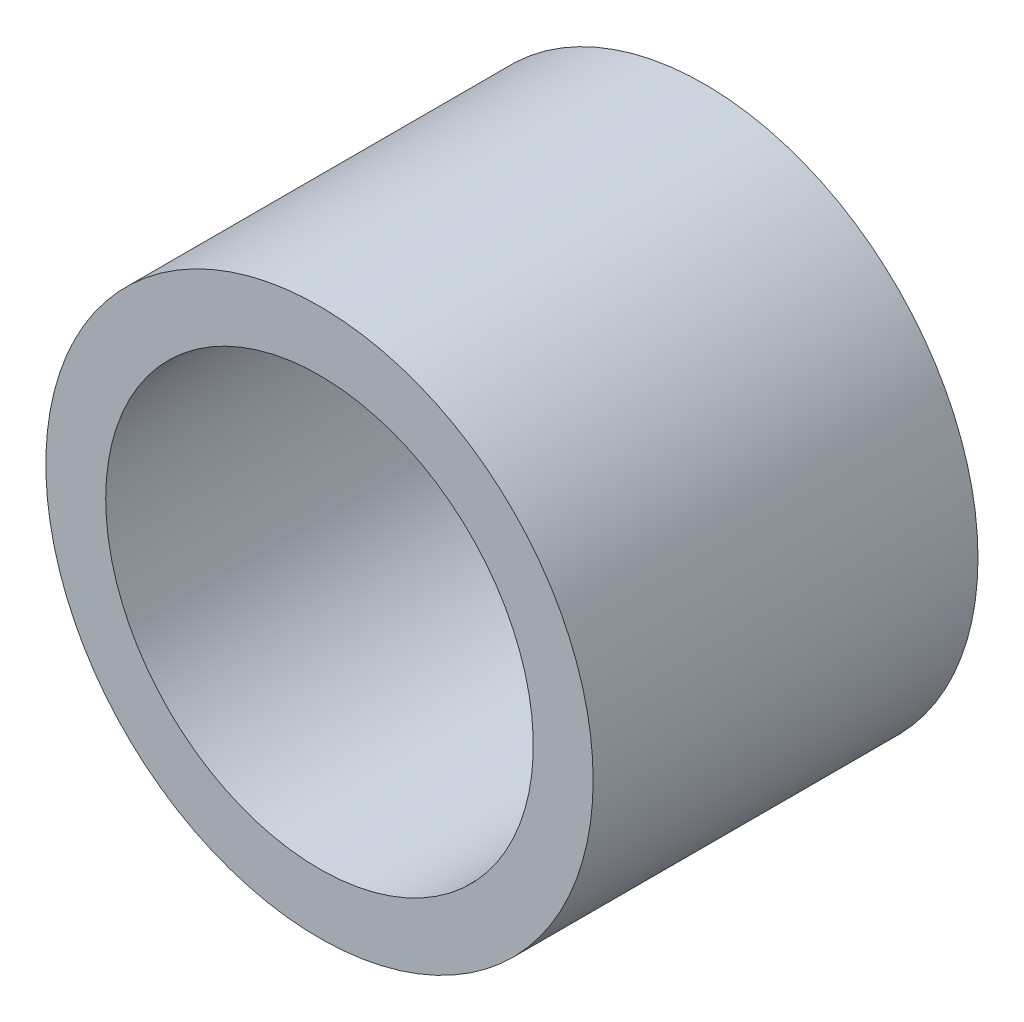
from build123d import *

# Parameters (mm, degrees)
SKETCH_1_R          = 16
EXTRUDE_1_DEPTH     = 22.5
SKETCH_2_R          = 15
CUT_EXTRUDE_3_DEPTH = 4
SKETCH_3_R          = 12.5
CUT_EXTRUDE_4_DEPTH = 19.5


with BuildPart() as part:
    # Эскиз1 → Вытянуть1 (new body)
    with BuildSketch(Plane.XY):
        Circle(SKETCH_1_R)
    extrude(amount=EXTRUDE_1_DEPTH)

    # Эскиз2 → Вытянуть3 (cut)
    with BuildSketch(Plane(origin=(0, 0, 0), x_dir=(-1, 0, 0), z_dir=(0, 0, -1))):
        Circle(SKETCH_2_R)
    extrude(amount=-CUT_EXTRUDE_3_DEPTH, mode=Mode.SUBTRACT)

    # Эскиз3 → Вытянуть4 (cut, through all)
    with BuildSketch(Plane(origin=(0, 0, 4), x_dir=(-1, 0, 0), z_dir=(0, 0, -1))):
        Circle(SKETCH_3_R)
    extrude(amount=-CUT_EXTRUDE_4_DEPTH, mode=Mode.SUBTRACT)


solid = part.part
